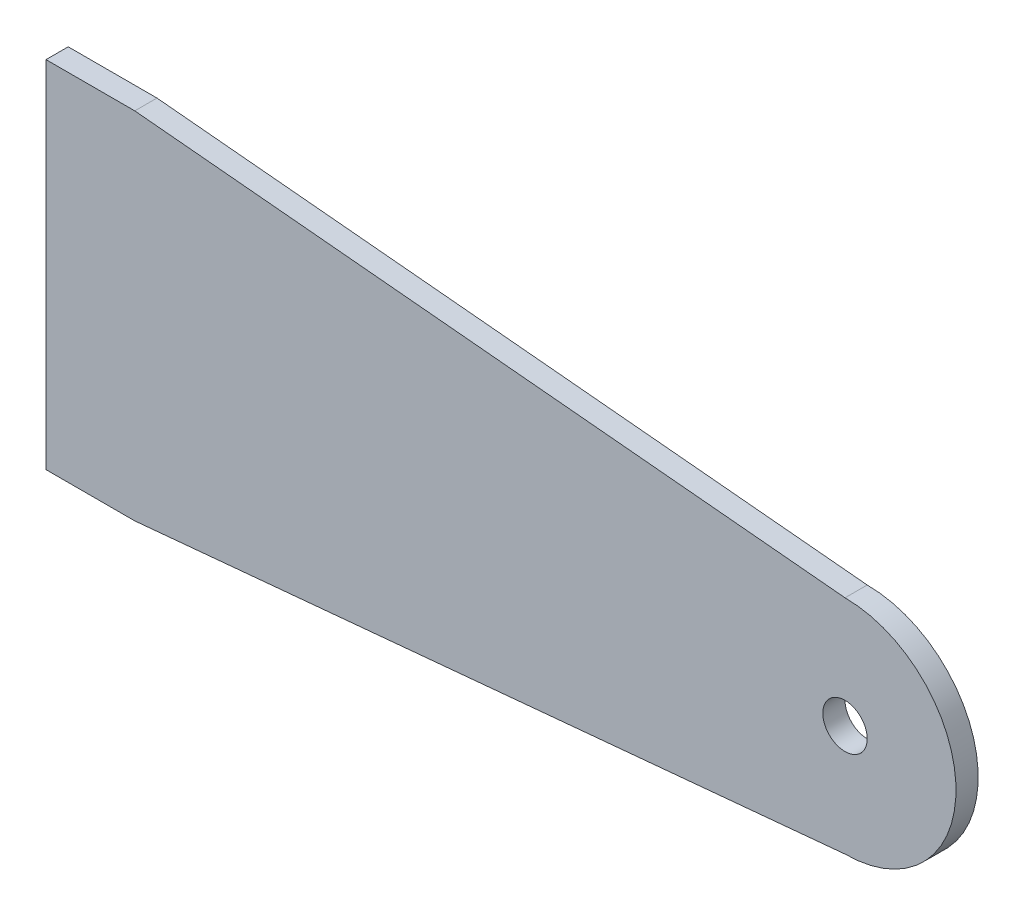
from build123d import *

# Parameters (mm, degrees)
SKETCH1_R           = 3.175
BOSS_EXTRUDE1_DEPTH = 3.175


with BuildPart() as part:
    # Sketch1 → Boss-Extrude1 (new body)
    with BuildSketch(Plane.XY.offset(50.8)):
        with BuildLine():
            Line((101.6, 15.875), (0, 25.4))
            Line((0, 25.4), (-12.7, 25.4))
            Line((-12.7, 25.4), (-12.7, -25.4))
            Line((-12.7, -25.4), (0, -25.4))
            Line((0, -25.4), (101.6, -15.875))
            ThreePointArc((101.6, -15.875), (117.475, 0), (101.6, 15.875))
        make_face()
        with Locations((101.6, 0)):
            Circle(SKETCH1_R, mode=Mode.SUBTRACT)
    extrude(amount=BOSS_EXTRUDE1_DEPTH)


solid = part.part
